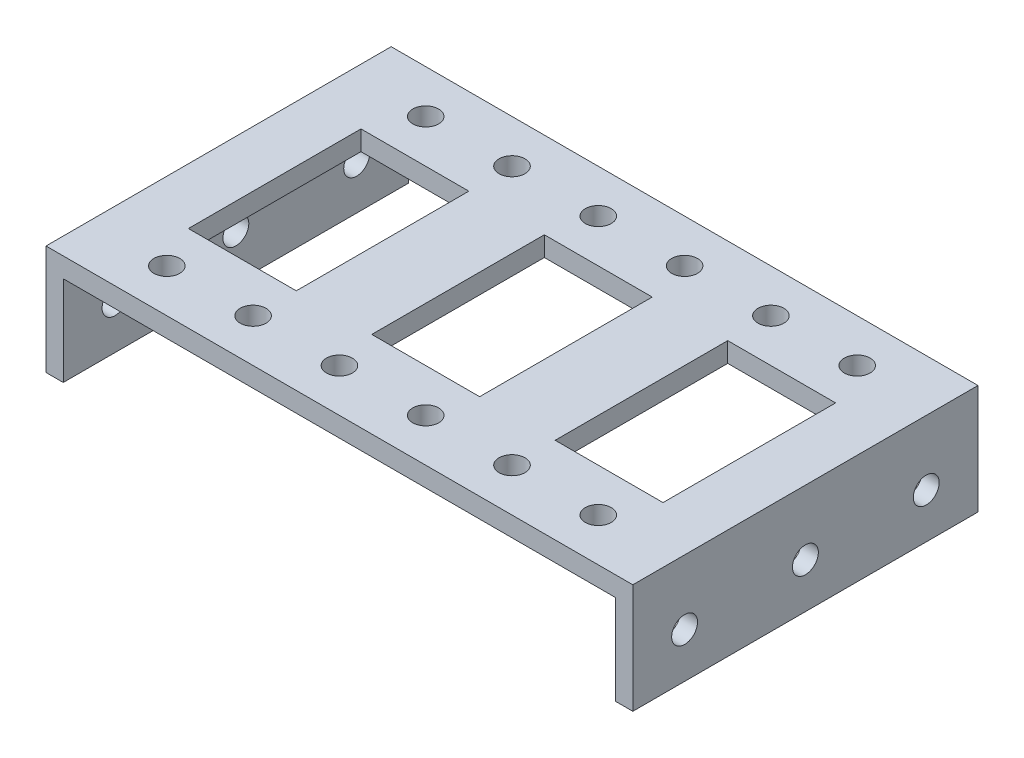
from build123d import *

# Parameters (mm, degrees)
BOSS_EXTRUDE1_DEPTH   = 20
F_3_0MM_DOWEL_HOLE1_D = 3
F_3_0MM_DOWEL_HOLE2_D = 3
SKETCH10_W            = 12.5
SKETCH10_H            = 20
CUT_EXTRUDE1_DEPTH    = 10
SKETCH11_W            = 12.5
SKETCH11_H            = 20
CUT_EXTRUDE2_DEPTH    = 10


with BuildPart() as part:
    # Sketch1 → Boss-Extrude1 (new body, symmetric)
    with BuildSketch(Plane.XY):
        Polygon((-34, 0), (-34, 12.7), (34, 12.7), (34, 0), (32, 0), (32, 10.414), (-32, 10.414), (-32, 0), align=None)
    extrude(amount=BOSS_EXTRUDE1_DEPTH, both=True)

    # Ø3.0mm Dowel Hole1 (through all)
    with Locations(Plane(origin=(34, 0, 0), x_dir=(0, 0, -1), z_dir=(1, 0, 0))):
        with Locations((-14, 5.207), (14, 5.207), (0, 5.207)):
            Hole(F_3_0MM_DOWEL_HOLE1_D / 2)

    # Ø3.0mm Dowel Hole2 (through all)
    with Locations(Plane(origin=(0, 12.7, 0), x_dir=(1, 0, 0), z_dir=(0, 1, 0))):
        with Locations((25, -15), (15, -15), (5, -15), (25, 15), (15, 15), (5, 15)):
            f_3_0mm_dowel_hole2 = Hole(F_3_0MM_DOWEL_HOLE2_D / 2)

    # Sketch10 → Cut-Extrude1 (cut)
    with BuildSketch(Plane(origin=(0, 12.7, 0), x_dir=(1, 0, 0), z_dir=(0, 1, 0))):
        with Locations((-21.25, 0)):
            Rectangle(SKETCH10_W, SKETCH10_H)
    cut_extrude1 = extrude(amount=-CUT_EXTRUDE1_DEPTH, mode=Mode.SUBTRACT)

    # Mirror1: Cut-Extrude1 across plane
    add(cut_extrude1.mirror(Plane(origin=(0, 0, 0), x_dir=(0, 0, 1), z_dir=(1, 0, 0))), mode=Mode.SUBTRACT)

    # Sketch11 → Cut-Extrude2 (cut)
    with BuildSketch(Plane(origin=(0, 12.7, 0), x_dir=(1, 0, 0), z_dir=(0, 1, 0))):
        Rectangle(SKETCH11_W, SKETCH11_H)
    extrude(amount=-CUT_EXTRUDE2_DEPTH, mode=Mode.SUBTRACT)

    # Mirror2: Ø3.0mm Dowel Hole2 across plane
    add(f_3_0mm_dowel_hole2.mirror(Plane(origin=(0, 0, 0), x_dir=(0, 0, 1), z_dir=(1, 0, 0))), mode=Mode.SUBTRACT)


solid = part.part
